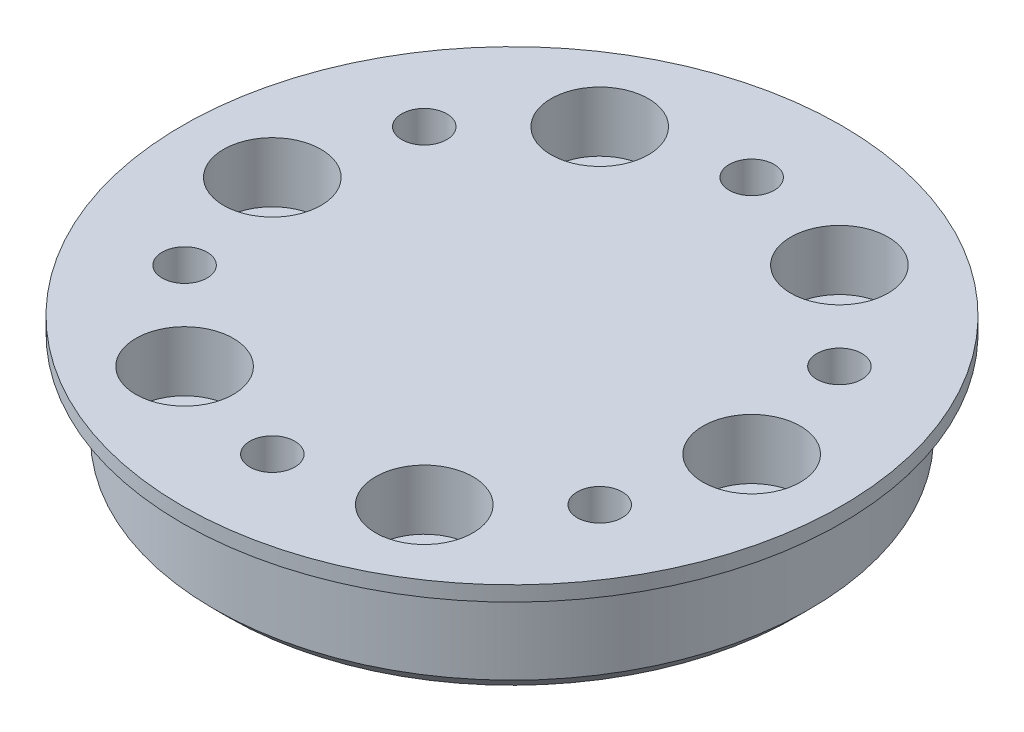
from build123d import *

# Parameters (mm, degrees)
SKETCH1_R           = 19.9
BOSS_EXTRUDE1_DEPTH = 7
SKETCH2_R           = 22
BOSS_EXTRUDE2_DEPTH = 1
SKETCH3_R           = 1.5
SKETCH3_R_2         = 1.6
CUT_EXTRUDE1_DEPTH  = 9
SKETCH4_R           = 3.25
CUT_EXTRUDE2_DEPTH  = 4
CHAMFER1_SIZE       = 1


with BuildPart() as part:
    # Sketch1 → Boss-Extrude1 (new body)
    with BuildSketch(Plane(origin=(0, 0, 0), x_dir=(1, 0, 0), z_dir=(0, 1, 0))):
        Circle(SKETCH1_R)
    extrude(amount=BOSS_EXTRUDE1_DEPTH)

    # Sketch2 → Boss-Extrude2 (add)
    with BuildSketch(Plane(origin=(0, 7, 0), x_dir=(1, 0, 0), z_dir=(0, 1, 0))):
        Circle(SKETCH2_R)
    extrude(amount=BOSS_EXTRUDE2_DEPTH)

    # Sketch3 → Cut-Extrude1 (cut, through all)
    with BuildSketch(Plane(origin=(0, 8, 0), x_dir=(1, 0, 0), z_dir=(0, 1, 0))):
        with Locations((0, 16)):
            Circle(SKETCH3_R)
        with Locations((13.856406461, 8)):
            Circle(SKETCH3_R)
        with Locations((13.856406461, -8)):
            Circle(SKETCH3_R)
        with Locations((0, -16)):
            Circle(SKETCH3_R)
        with Locations((-13.856406461, -8)):
            Circle(SKETCH3_R)
        with Locations((-13.856406461, 8)):
            Circle(SKETCH3_R)
        with Locations((-8, 13.856406461)):
            Circle(SKETCH3_R_2)
        with Locations((-16, 0)):
            Circle(SKETCH3_R_2)
        with Locations((-8, -13.856406461)):
            Circle(SKETCH3_R_2)
        with Locations((8, -13.856406461)):
            Circle(SKETCH3_R_2)
        with Locations((16, 0)):
            Circle(SKETCH3_R_2)
        with Locations((8, 13.856406461)):
            Circle(SKETCH3_R_2)
    extrude(amount=-CUT_EXTRUDE1_DEPTH, mode=Mode.SUBTRACT)

    # Sketch4 → Cut-Extrude2 (cut)
    with BuildSketch(Plane(origin=(0, 8, 0), x_dir=(1, 0, 0), z_dir=(0, 1, 0))):
        with Locations((-8, 13.856406461)):
            Circle(SKETCH4_R)
        with Locations((8, 13.856406461)):
            Circle(SKETCH4_R)
        with Locations((16, 0)):
            Circle(SKETCH4_R)
        with Locations((8, -13.856406461)):
            Circle(SKETCH4_R)
        with Locations((-8, -13.856406461)):
            Circle(SKETCH4_R)
        with Locations((-16, 0)):
            Circle(SKETCH4_R)
    extrude(amount=-CUT_EXTRUDE2_DEPTH, mode=Mode.SUBTRACT)

    # Chamfer1
    chamfer1_edges = [part.edges().sort_by_distance(p)[0] for p in [
        (-19.9, 0, 0),
    ]]
    chamfer(chamfer1_edges, length=CHAMFER1_SIZE)


solid = part.part
